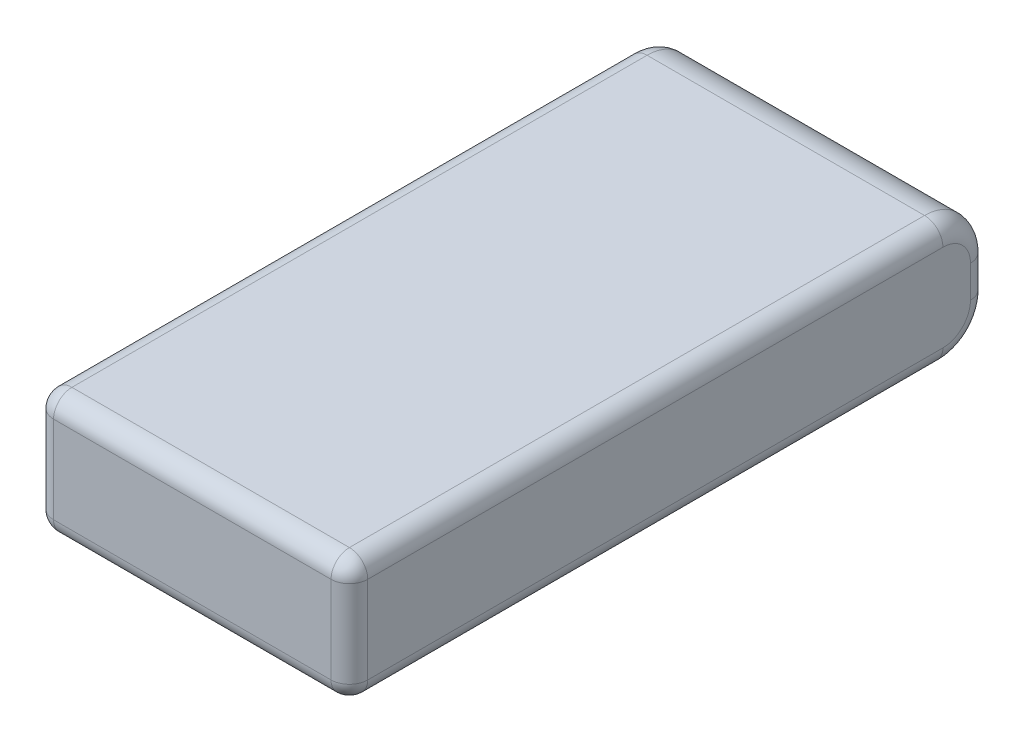
from build123d import *

# Parameters (mm, degrees)
SKETCH1_W           = 34.25
SKETCH1_H           = 69.7
BOSS_EXTRUDE1_DEPTH = 13.5
FILLET1_R           = 5
FILLET2_R           = 2


with BuildPart() as part:
    # Sketch1 → Boss-Extrude1 (new body)
    with BuildSketch(Plane(origin=(0, 0, 0), x_dir=(1, 0, 0), z_dir=(0, 1, 0))):
        with Locations((17.125, 34.85)):
            Rectangle(SKETCH1_W, SKETCH1_H)
    extrude(amount=BOSS_EXTRUDE1_DEPTH)

    # Fillet1
    fillet1_edges = [part.edges().sort_by_distance(p)[0] for p in [
        (17.125, 13.5, -69.7),
        (17.125, 0, -69.7),
    ]]
    fillet(fillet1_edges, radius=FILLET1_R)

    # Fillet2
    fillet2_edges = [part.edges().sort_by_distance(p)[0] for p in [
        (34.25, 13.5, -32.35),
        (0, 6.75, -69.7),
        (34.25, 6.75, -69.7),
        (0, 0, -32.35),
        (0, 13.5, -32.35),
        (0, 12.035533906, -68.235533906),
        (0, 1.464466094, -68.235533906),
        (34.25, 12.035533906, -68.235533906),
        (34.25, 1.464466094, -68.235533906),
        (34.25, 0, -32.35),
        (17.125, 0, 0),
        (17.125, 13.5, 0),
        (34.25, 6.75, 0),
        (0, 6.75, 0),
    ]]
    fillet(fillet2_edges, radius=FILLET2_R)


solid = part.part
